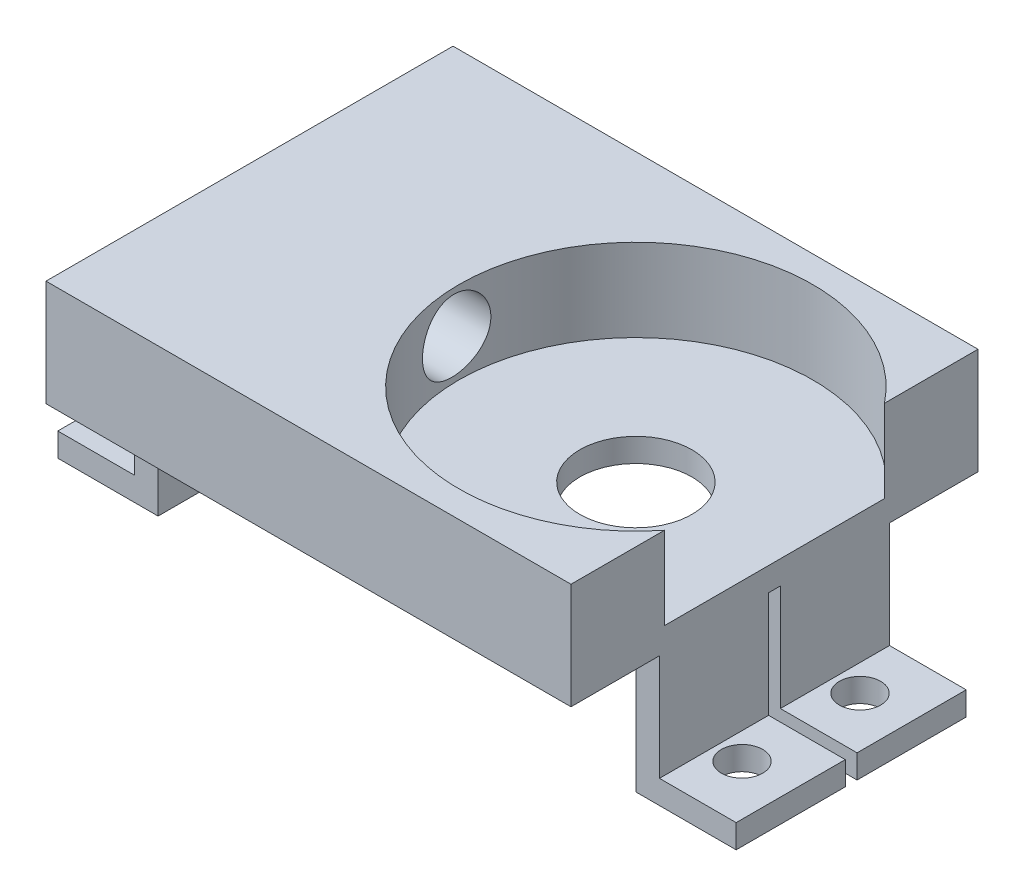
from build123d import *

# Parameters (mm, degrees)
BOSS_EXTRUDE1_DEPTH = 34.5
SKETCH3_R           = 15
CUT_EXTRUDE1_DEPTH  = 7
SKETCH4_W           = 7.5
SKETCH4_H           = 11
CUT_EXTRUDE2_DEPTH  = 58.5
SKETCH5_R           = 4.75
CUT_EXTRUDE3_DEPTH  = 14
SKETCH6_W           = 1
SKETCH6_H           = 11
CUT_EXTRUDE4_DEPTH  = 58.5
CUT_EXTRUDE5_REACH  = 53
SKETCH7_R           = 3
SKETCH8_R           = 1.75
CUT_EXTRUDE6_DEPTH  = 3


with BuildPart() as part:
    # Sketch1 → Boss-Extrude1 (new body)
    with BuildSketch(Plane.XY):
        Polygon((-9.056756757, 11), (31.443243243, 11), (31.443243243, 0), (39.943243243, 0), (39.943243243, 2), (33.443243243, 2), (33.443243243, 20), (-11.056756757, 20), (-11.056756757, 2), (-17.556756757, 2), (-17.556756757, 0), (-9.056756757, 0), align=None)
    extrude(amount=BOSS_EXTRUDE1_DEPTH)

    # Sketch3 → Cut-Extrude1 (cut)
    with BuildSketch(Plane(origin=(0, 20, 0), x_dir=(1, 0, 0), z_dir=(0, 1, 0))):
        with Locations((21.693243243, -17.25)):
            Circle(SKETCH3_R)
    extrude(amount=-CUT_EXTRUDE1_DEPTH, mode=Mode.SUBTRACT)

    # Sketch4 → Cut-Extrude2 (cut, through all)
    with BuildSketch(Plane.ZY.offset(17.556756757)):
        with Locations((3.75, 5.5)):
            Rectangle(SKETCH4_W, SKETCH4_H)
        with Locations((30.75, 5.5)):
            Rectangle(SKETCH4_W, SKETCH4_H)
    extrude(amount=-CUT_EXTRUDE2_DEPTH, mode=Mode.SUBTRACT)

    # Sketch5 → Cut-Extrude3 (cut, through all)
    with BuildSketch(Plane(origin=(0, 13, 0), x_dir=(1, 0, 0), z_dir=(0, 1, 0))):
        with Locations((21.693243243, -17.25)):
            Circle(SKETCH5_R)
    extrude(amount=-CUT_EXTRUDE3_DEPTH, mode=Mode.SUBTRACT)

    # Sketch6 → Cut-Extrude4 (cut, through all)
    with BuildSketch(Plane(origin=(39.943243243, 0, 0), x_dir=(0, 0, -1), z_dir=(1, 0, 0))):
        with Locations((-17.25, 5.5)):
            Rectangle(SKETCH6_W, SKETCH6_H)
    extrude(amount=-CUT_EXTRUDE4_DEPTH, mode=Mode.SUBTRACT)

    # Sketch7 → Cut-Extrude5 (cut, up to next)
    with BuildSketch(Plane.ZY.offset(11.056756757), mode=Mode.PRIVATE) as cut_extrude5_sk1:
        with Locations((17.75, 16.5)):
            Circle(SKETCH7_R)
    cut_extrude5_tool1 = extrude(cut_extrude5_sk1.sketch, amount=-CUT_EXTRUDE5_REACH, mode=Mode.PRIVATE) & part.part
    add(cut_extrude5_tool1.solids().sort_by_distance((-11.056757, 16.5, 17.75))[0], mode=Mode.SUBTRACT)

    # Sketch8 → Cut-Extrude6 (cut, through all)
    with BuildSketch(Plane(origin=(0, 2, 0), x_dir=(1, 0, 0), z_dir=(0, 1, 0))):
        with Locations((-13.306756757, -12.25)):
            Circle(SKETCH8_R)
        with Locations((-13.306756757, -22.25)):
            Circle(SKETCH8_R)
        with Locations((35.693243243, -22.25)):
            Circle(SKETCH8_R)
        with Locations((35.693243243, -12.25)):
            Circle(SKETCH8_R)
    extrude(amount=-CUT_EXTRUDE6_DEPTH, mode=Mode.SUBTRACT)


solid = part.part
